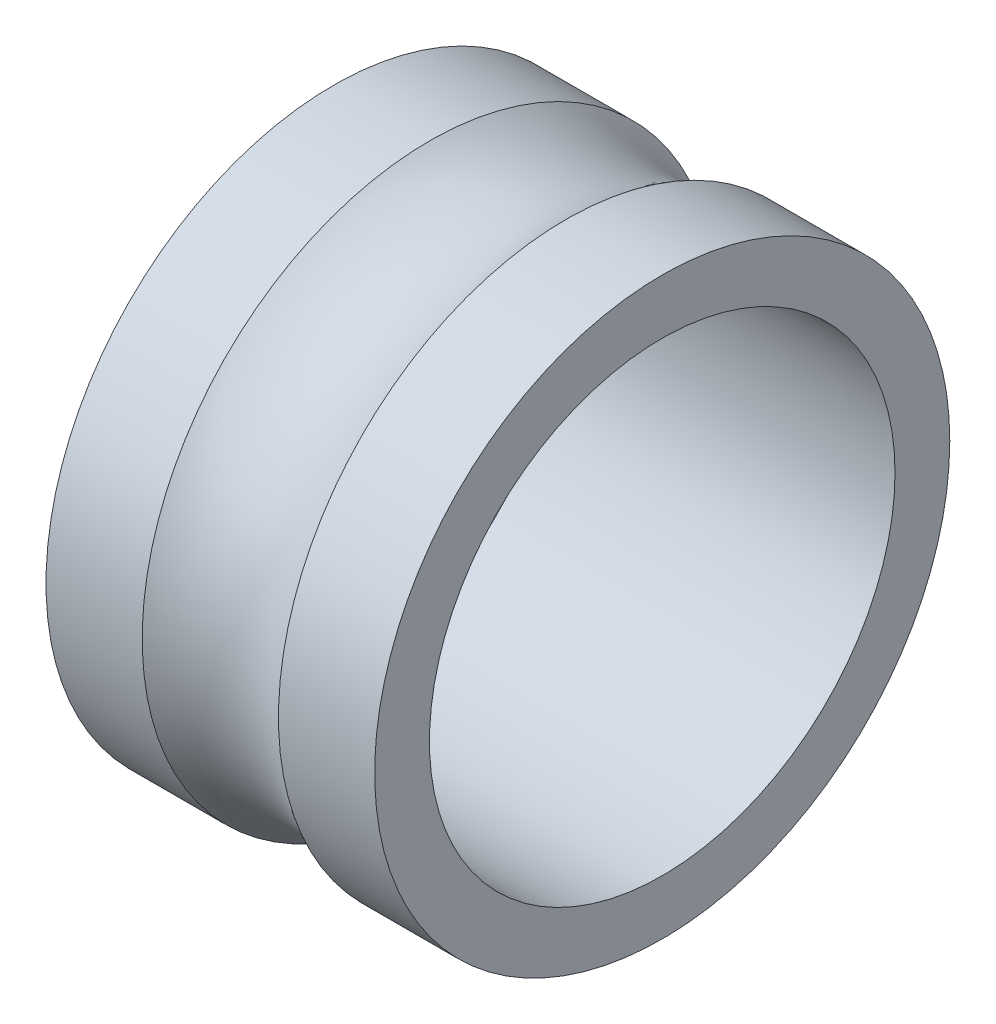
from build123d import *


with BuildPart() as part:
    # 草图1 → 旋转1 (revolve)
    with BuildSketch(Plane.XY):
        with BuildLine():
            Line((6, -5.75), (-6, -5.75))
            Line((-6, -5.75), (-6, -3.75))
            Line((-6, -3.75), (-2.487468593, -3.75))
            ThreePointArc((-2.487468593, -3.75), (0, -4.5), (2.487468593, -3.75))
            Line((2.487468593, -3.75), (6, -3.75))
            Line((6, -3.75), (6, -5.75))
        make_face()
    revolve(axis=Axis((0, -14.25, 0), (-1, 0, 0)))


solid = part.part
